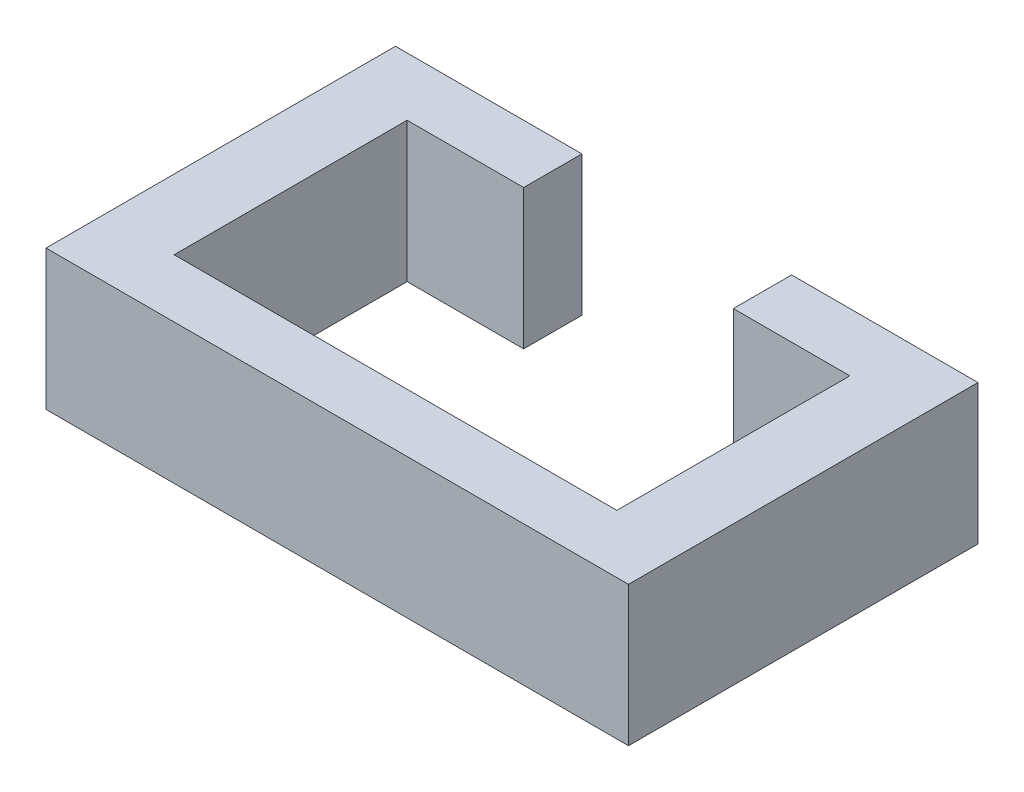
from build123d import *

# Parameters (mm, degrees)
BOSS_EXTRUDE1_DEPTH = 12


with BuildPart() as part:
    # Sketch1 → Boss-Extrude1 (new body)
    with BuildSketch(Plane(origin=(0, 0, 0), x_dir=(1, 0, 0), z_dir=(0, 1, 0))):
        Polygon((-25, 10), (-9, 10), (-9, 5), (-19, 5), (-19, -15), (19, -15), (19, 5), (9, 5), (9, 10), (25, 10), (25, -20), (-25, -20), align=None)
    extrude(amount=BOSS_EXTRUDE1_DEPTH)


solid = part.part
